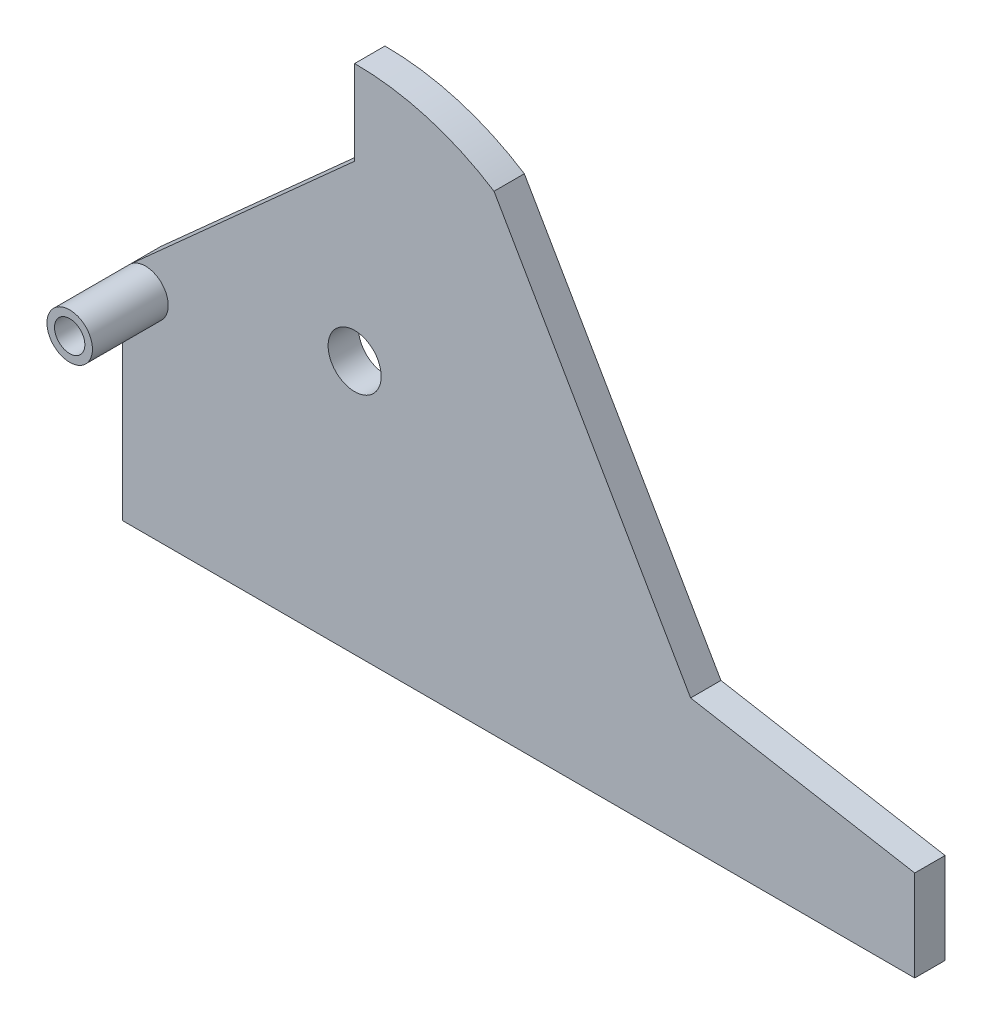
from build123d import *

# Parameters (mm, degrees)
SKETCH1_R           = 17.5
SKETCH1_R_2         = 10
BOSS_EXTRUDE1_DEPTH = 20
SKETCH2_R           = 15
SKETCH2_R_2         = 10
BOSS_EXTRUDE2_DEPTH = 50


with BuildPart() as part:
    # Sketch1 → Boss-Extrude1 (new body)
    with BuildSketch(Plane.XY):
        with BuildLine():
            Line((0, 138), (0, 0))
            Line((0, 0), (522.5, 0))
            Line((522.5, 0), (522.5, 60))
            Line((522.5, 60), (374.649400312, 86.070049839))
            Line((374.649400312, 86.070049839), (244.94, 310.733321399))
            ThreePointArc((244.94, 310.733321399), (200.912248971, 330.848790378), (153, 337.740187298))
            Line((153, 337.740187298), (153, 281.918848091))
            Line((153, 281.918848091), (4.984782256, 149.166710059))
            ThreePointArc((4.984782256, 149.166710059), (1.302769146, 144.114398329), (0, 138))
        make_face()
        with Locations((153, 167.740187298)):
            Circle(SKETCH1_R, mode=Mode.SUBTRACT)
        with Locations((15, 138)):
            Circle(SKETCH1_R_2, mode=Mode.SUBTRACT)
    extrude(amount=BOSS_EXTRUDE1_DEPTH)

    # Sketch2 → Boss-Extrude2 (add)
    with BuildSketch(Plane.XY.offset(20)):
        with Locations((15, 138)):
            Circle(SKETCH2_R)
        with Locations((15, 138)):
            Circle(SKETCH2_R_2, mode=Mode.SUBTRACT)
    extrude(amount=BOSS_EXTRUDE2_DEPTH)


solid = part.part
